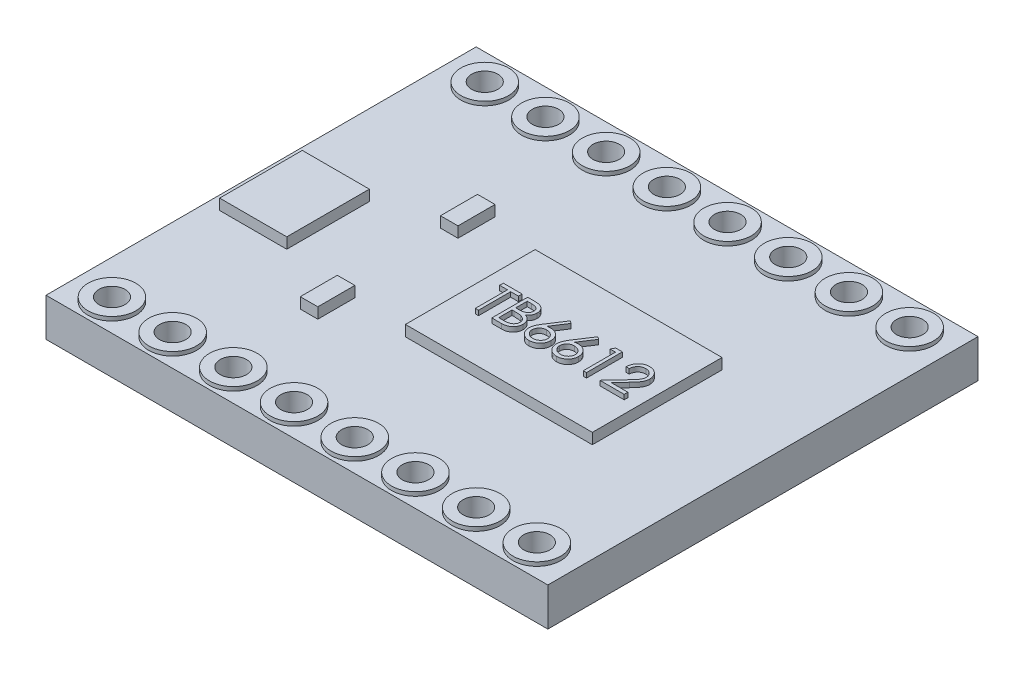
from build123d import *

# Parameters (mm, degrees)
SKETCH1_W           = 21
SKETCH1_H           = 18
SKETCH1_R           = 1
SKETCH1_W_2         = 7.822024276
SKETCH1_H_2         = 5.426675314
SKETCH1_W_3         = 2.807623522
SKETCH1_H_3         = 3.457148366
SKETCH1_W_4         = 0.733334502
SKETCH1_H_4         = 1.550478661
SKETCH1_H_5         = 1.550478662
BOSS_EXTRUDE1_DEPTH = 1.6
SKETCH1_4_W         = 0.733334502
SKETCH1_4_H         = 1.550478661
SKETCH1_4_W_2       = 2.807623522
SKETCH1_4_H_2       = 3.457148366
SKETCH1_4_H_3       = 1.550478662
SKETCH1_4_W_3       = 7.822024276
SKETCH1_4_H_4       = 5.426675314
BOSS_EXTRUDE2_DEPTH = 2.05
BOSS_EXTRUDE3_DEPTH = 0.2
SKETCH1_6_R         = 1
SKETCH1_6_R_2       = 0.55
BOSS_EXTRUDE4_DEPTH = 1.766276616


with BuildPart() as part:
    # Sketch1 → Boss-Extrude1 (new body)
    with BuildSketch(Plane(origin=(0, 0, 0), x_dir=(1, 0, 0), z_dir=(0, 1, 0))):
        with Locations((61.705593343, 83.060982754)):
            Rectangle(SKETCH1_W, SKETCH1_H)
        with Locations((52.815593343, 90.810982754)):
            Circle(SKETCH1_R, mode=Mode.SUBTRACT)
        with Locations((55.355593343, 90.810982754)):
            Circle(SKETCH1_R, mode=Mode.SUBTRACT)
        with Locations((57.895593343, 90.810982754)):
            Circle(SKETCH1_R, mode=Mode.SUBTRACT)
        with Locations((60.435593343, 90.810982754)):
            Circle(SKETCH1_R, mode=Mode.SUBTRACT)
        with Locations((62.975593343, 90.810982754)):
            Circle(SKETCH1_R, mode=Mode.SUBTRACT)
        with Locations((65.515593343, 90.810982754)):
            Circle(SKETCH1_R, mode=Mode.SUBTRACT)
        with Locations((68.055593343, 90.810982754)):
            Circle(SKETCH1_R, mode=Mode.SUBTRACT)
        with Locations((70.595593343, 90.810982754)):
            Circle(SKETCH1_R, mode=Mode.SUBTRACT)
        with Locations((55.355593343, 75.210982754)):
            Circle(SKETCH1_R, mode=Mode.SUBTRACT)
        with Locations((57.895593343, 75.210982754)):
            Circle(SKETCH1_R, mode=Mode.SUBTRACT)
        with Locations((60.435593343, 75.210982754)):
            Circle(SKETCH1_R, mode=Mode.SUBTRACT)
        with Locations((62.975593343, 75.210982754)):
            Circle(SKETCH1_R, mode=Mode.SUBTRACT)
        with Locations((65.515593343, 75.210982754)):
            Circle(SKETCH1_R, mode=Mode.SUBTRACT)
        with Locations((68.055593343, 75.210982754)):
            Circle(SKETCH1_R, mode=Mode.SUBTRACT)
        with Locations((70.595593343, 75.210982754)):
            Circle(SKETCH1_R, mode=Mode.SUBTRACT)
        with Locations((52.815593343, 75.210982754)):
            Circle(SKETCH1_R, mode=Mode.SUBTRACT)
        with Locations((64.144581205, 82.786474506)):
            Rectangle(SKETCH1_W_2, SKETCH1_H_2, mode=Mode.SUBTRACT)
        with Locations((53.172605435, 82.493140705)):
            Rectangle(SKETCH1_W_3, SKETCH1_H_3, mode=Mode.SUBTRACT)
        with Locations((57.394516924, 85.520764576)):
            Rectangle(SKETCH1_W_4, SKETCH1_H_4, mode=Mode.SUBTRACT)
        with Locations((57.394516924, 79.654088562)):
            Rectangle(SKETCH1_W_4, SKETCH1_H_5, mode=Mode.SUBTRACT)
    extrude(amount=BOSS_EXTRUDE1_DEPTH)

    # Sketch1_4 → Boss-Extrude2 (add)
    with BuildSketch(Plane(origin=(0, 0, 0), x_dir=(1, 0, 0), z_dir=(0, 1, 0))):
        with Locations((57.394516924, 85.520764576)):
            Rectangle(SKETCH1_4_W, SKETCH1_4_H)
        with Locations((53.172605435, 82.493140705)):
            Rectangle(SKETCH1_4_W_2, SKETCH1_4_H_2)
        with Locations((57.394516924, 79.654088562)):
            Rectangle(SKETCH1_4_W, SKETCH1_4_H_3)
        with Locations((64.144581205, 82.786474506)):
            Rectangle(SKETCH1_4_W_3, SKETCH1_4_H_4)
    extrude(amount=BOSS_EXTRUDE2_DEPTH)

    # Sketch3 → Boss-Extrude3 (add)
    with BuildSketch(Plane(origin=(0, 2.05, 0), x_dir=(1, 0, 0), z_dir=(0, 1, 0))):
        Polygon((60.986398195, 83.262831821), (60.986398195, 83.416677975), (61.774859733, 83.416677975), (61.774859733, 83.262831821), (61.447936656, 83.262831821), (61.447936656, 81.916677975), (61.313321272, 81.916677975), (61.313321272, 83.262831821), align=None)
        with BuildLine():
            Line((62.005628964, 83.416677975), (62.298297233, 83.416677975))
            add(Edge.make_bspline(
                [(62.298297233, 83.416677975), (62.312623724, 83.416602653), (62.340392028, 83.416456661), (62.380771789, 83.414192462), (62.418592708, 83.411105175), (62.453865753, 83.406206564), (62.486574626, 83.400295802), (62.516817899, 83.393137881), (62.544499401, 83.384555047), (62.577547717, 83.37090664), (62.615228, 83.350625283), (62.656027311, 83.320655898), (62.690914842, 83.283999128), (62.720994693, 83.242649418), (62.744909458, 83.197162659), (62.762210586, 83.148623006), (62.773163961, 83.097656546), (62.774290432, 83.062666612), (62.774859733, 83.044983263)],
                knots=[0, 0, 0, 0, 4.2973e-05, 8.3292e-05, 0.000121297, 0.00015678, 0.000190079, 0.000220981, 0.000249966, 0.000276917, 0.000328141, 0.000377961, 0.000428112, 0.000479321, 0.000530933, 0.000581687, 0.000633546, 0.000686534, 0.000686534, 0.000686534, 0.000686534], degree=3))
            add(Edge.make_bspline(
                [(62.774859733, 83.044983263), (62.774391211, 83.028417882), (62.773470521, 82.995865346), (62.764666481, 82.948253585), (62.750883337, 82.902931634), (62.731723945, 82.860064898), (62.706823089, 82.820621921), (62.677312381, 82.784284521), (62.641708037, 82.752591211), (62.615032363, 82.734872824), (62.601482329, 82.725872686)],
                knots=[0, 0, 0, 0, 4.9653e-05, 9.7573e-05, 0.000144717, 0.000191519, 0.000237957, 0.000284279, 0.000331517, 0.000380282, 0.000380282, 0.000380282, 0.000380282], degree=3))
            add(Edge.make_bspline(
                [(62.601482329, 82.725872686), (62.618522513, 82.719330544), (62.651124604, 82.706813805), (62.695990038, 82.68468432), (62.734644972, 82.660614844), (62.767386606, 82.634329766), (62.795388458, 82.605997418), (62.819839719, 82.575202369), (62.840703165, 82.541542902), (62.858580132, 82.505369958), (62.872529599, 82.4670529), (62.882976415, 82.426951139), (62.888962465, 82.385208472), (62.889814311, 82.356800453), (62.890244349, 82.342459225)],
                knots=[0, 0, 0, 0, 5.4738e-05, 0.000104727, 0.000149828, 0.000191077, 0.000230385, 0.000269101, 0.000308787, 0.000348967, 0.000389939, 0.000430898, 0.000473095, 0.000516115, 0.000516115, 0.000516115, 0.000516115], degree=3))
            add(Edge.make_bspline(
                [(62.890244349, 82.342459225), (62.8898257, 82.32781628), (62.889001998, 82.299005875), (62.882924867, 82.256682246), (62.87263525, 82.21623584), (62.858461902, 82.177405047), (62.839963767, 82.14026499), (62.817451782, 82.104773591), (62.790609683, 82.071287449), (62.760582739, 82.039434468), (62.726613249, 82.010793988), (62.689963639, 81.985287256), (62.650172359, 81.964310372), (62.607892933, 81.94668922), (62.562651084, 81.933228992), (62.514649966, 81.923812175), (62.46393098, 81.917467159), (62.429126801, 81.9169455), (62.411278002, 81.916677975)],
                knots=[0, 0, 0, 0, 4.3921e-05, 8.6415e-05, 0.000127955, 0.000168928, 0.000210182, 0.000252195, 0.000294758, 0.000338753, 0.000383306, 0.000427814, 0.000472444, 0.000517978, 0.000565035, 0.00061377, 0.000664607, 0.000718123, 0.000718123, 0.000718123, 0.000718123], degree=3))
            Line((62.411278002, 81.916677975), (62.005628964, 81.916677975))
            Line((62.005628964, 81.916677975), (62.005628964, 83.416677975))
        make_face()
        with BuildLine():
            Line((62.140244349, 83.262831821), (62.140244349, 82.78206259))
            Line((62.140244349, 82.78206259), (62.23068906, 82.78206259))
            add(Edge.make_bspline(
                [(62.23068906, 82.78206259), (62.243909972, 82.782233986), (62.269455469, 82.782565157), (62.306449711, 82.783513807), (62.340789004, 82.786170111), (62.372414075, 82.788825652), (62.401275123, 82.793143333), (62.427308206, 82.798282814), (62.450921891, 82.803718345), (62.478153125, 82.812962411), (62.509041531, 82.826624271), (62.541970004, 82.847826487), (62.570999063, 82.873079781), (62.595512143, 82.902218765), (62.615574202, 82.934304273), (62.629508651, 82.968824365), (62.638957487, 83.004918707), (62.639811001, 83.029697958), (62.640244349, 83.042278936)],
                knots=[0, 0, 0, 0, 3.9668e-05, 7.6647e-05, 0.000110986, 0.000142978, 0.000171832, 0.000198468, 0.000222591, 0.000244446, 0.000284658, 0.000323582, 0.000361488, 0.000399654, 0.00043743, 0.000474482, 0.000510993, 0.000548651, 0.000548651, 0.000548651, 0.000548651], degree=3))
            add(Edge.make_bspline(
                [(62.640244349, 83.042278936), (62.640018843, 83.050604267), (62.639576489, 83.066935312), (62.635953645, 83.090742178), (62.629796113, 83.113132358), (62.62188713, 83.134412691), (62.610834835, 83.15391777), (62.597821922, 83.172321996), (62.582099483, 83.188998619), (62.564203492, 83.204585546), (62.543628368, 83.21840463), (62.520386386, 83.230507814), (62.494163096, 83.240253861), (62.465400443, 83.248789355), (62.433655692, 83.254784338), (62.399295169, 83.259778647), (62.362037432, 83.262321251), (62.33626096, 83.262657835), (62.322936656, 83.262831821)],
                knots=[0, 0, 0, 0, 2.4969e-05, 4.8979e-05, 7.2012e-05, 9.4557e-05, 0.000116883, 0.000139064, 0.000162027, 0.00018546, 0.000210129, 0.000236202, 0.00026388, 0.000293928, 0.000326104, 0.000360694, 0.000398052, 0.000438026, 0.000438026, 0.000438026, 0.000438026], degree=3))
            Line((62.322936656, 83.262831821), (62.140244349, 83.262831821))
        make_face(mode=Mode.SUBTRACT)
        with BuildLine():
            Line((62.140244349, 82.628216436), (62.140244349, 82.070524129))
            Line((62.140244349, 82.070524129), (62.331951079, 82.070524129))
            add(Edge.make_bspline(
                [(62.331951079, 82.070524129), (62.345673476, 82.070688592), (62.372121587, 82.071005573), (62.410307828, 82.072040382), (62.445700587, 82.074394214), (62.47813836, 82.078099579), (62.507971411, 82.082118914), (62.534841855, 82.087523749), (62.558967509, 82.09371616), (62.586942213, 82.103287948), (62.618443716, 82.118157864), (62.652391226, 82.140578247), (62.682573891, 82.167288236), (62.708204716, 82.198201485), (62.729210283, 82.231814911), (62.744491192, 82.267448632), (62.753915845, 82.304513858), (62.755056775, 82.329785307), (62.755628964, 82.342459225)],
                knots=[0, 0, 0, 0, 4.117e-05, 7.935e-05, 0.000114589, 0.000147539, 0.000177285, 0.000204864, 0.000229717, 0.000251952, 0.000293486, 0.000333822, 0.000373623, 0.000413942, 0.000453884, 0.000492116, 0.000529866, 0.000567846, 0.000567846, 0.000567846, 0.000567846], degree=3))
            add(Edge.make_bspline(
                [(62.755628964, 82.342459225), (62.755510634, 82.350384942), (62.755275881, 82.366108534), (62.751735618, 82.389215314), (62.746586816, 82.411597831), (62.739930488, 82.433316863), (62.73023643, 82.453979738), (62.71891934, 82.473995121), (62.705650167, 82.493389469), (62.684974096, 82.517909007), (62.654900389, 82.546159155), (62.612168914, 82.573818084), (62.563580786, 82.596124288), (62.528340432, 82.605595492), (62.510136175, 82.610488071)],
                knots=[0, 0, 0, 0, 2.3755e-05, 4.7127e-05, 6.9942e-05, 9.2653e-05, 0.000115109, 0.000138254, 0.000161591, 0.000185483, 0.000234381, 0.000284718, 0.000337563, 0.000394031, 0.000394031, 0.000394031, 0.000394031], degree=3))
            add(Edge.make_bspline(
                [(62.510136175, 82.610488071), (62.502837992, 82.611968821), (62.487014023, 82.615179393), (62.461210775, 82.618568409), (62.431752545, 82.62158772), (62.398571312, 82.623821074), (62.361625094, 82.626129592), (62.320834986, 82.627027373), (62.276367566, 82.628098484), (62.245513692, 82.628176113), (62.229487137, 82.628216436)],
                knots=[0, 0, 0, 0, 2.2335e-05, 4.8427e-05, 7.8027e-05, 0.000111167, 0.000148186, 0.000189069, 0.000233549, 0.000281627, 0.000281627, 0.000281627, 0.000281627], degree=3))
            Line((62.229487137, 82.628216436), (62.140244349, 82.628216436))
        make_face(mode=Mode.SUBTRACT)
        with BuildLine():
            Line((63.755628964, 83.455139513), (63.859294829, 83.373709225))
            Line((63.859294829, 83.373709225), (63.462960695, 82.767639513))
            add(Edge.make_bspline(
                [(63.462960695, 82.767639513), (63.489347956, 82.771845454), (63.540819293, 82.780049616), (63.592918964, 82.781403021), (63.618309252, 82.78206259)],
                knots=[0, 0, 0, 0, 8.0061e-05, 0.000156168, 0.000156168, 0.000156168, 0.000156168], degree=3))
            add(Edge.make_bspline(
                [(63.618309252, 82.78206259), (63.633554608, 82.781652828), (63.663564637, 82.780846223), (63.707624695, 82.774638859), (63.74996281, 82.764856668), (63.790403501, 82.75059713), (63.829091922, 82.732381835), (63.866250092, 82.710550891), (63.901179525, 82.683977028), (63.93433003, 82.654292047), (63.964427358, 82.621413339), (63.991074238, 82.586527052), (64.013457149, 82.549669531), (64.031617401, 82.510859446), (64.045719492, 82.47015662), (64.055999911, 82.427613132), (64.06207688, 82.383199644), (64.06290209, 82.352994712), (64.063321272, 82.337651533)],
                knots=[0, 0, 0, 0, 4.5721e-05, 9.0001e-05, 0.000133222, 0.000175891, 0.000218368, 0.000261346, 0.000304916, 0.000349809, 0.000394681, 0.000438432, 0.000481307, 0.000523784, 0.000566737, 0.000610319, 0.000654897, 0.000700919, 0.000700919, 0.000700919, 0.000700919], degree=3))
            add(Edge.make_bspline(
                [(64.063321272, 82.337651533), (64.06271137, 82.316660231), (64.061511227, 82.275354317), (64.049552457, 82.215192871), (64.030969752, 82.157878936), (64.004407954, 82.104327577), (63.971415504, 82.05461219), (63.93118225, 82.010561276), (63.885135041, 81.971274117), (63.83306927, 81.93842128), (63.777036571, 81.911591401), (63.71817143, 81.892320583), (63.65704551, 81.880456239), (63.615557821, 81.878968838), (63.594571272, 81.878216436)],
                knots=[0, 0, 0, 0, 6.2904e-05, 0.00012378, 0.000183263, 0.000243197, 0.000302535, 0.000361677, 0.000421581, 0.000483597, 0.000545827, 0.000607495, 0.000668962, 0.000731884, 0.000731884, 0.000731884, 0.000731884], degree=3))
            add(Edge.make_bspline(
                [(63.594571272, 81.878216436), (63.574386971, 81.878871382), (63.534405407, 81.880168714), (63.475591352, 81.891725544), (63.41907863, 81.91045716), (63.365263181, 81.936263279), (63.31541149, 81.968859515), (63.270811931, 82.008100491), (63.231686885, 82.053147405), (63.199126333, 82.103993268), (63.173301163, 82.158631821), (63.153934052, 82.215604888), (63.142621376, 82.27470488), (63.141040566, 82.314768226), (63.140244349, 82.334947206)],
                knots=[0, 0, 0, 0, 6.0504e-05, 0.000119848, 0.000179046, 0.000238718, 0.000298389, 0.000357156, 0.000416376, 0.000476803, 0.000537689, 0.000597267, 0.000656906, 0.000717429, 0.000717429, 0.000717429, 0.000717429], degree=3))
            add(Edge.make_bspline(
                [(63.140244349, 82.334947206), (63.140750682, 82.350394884), (63.141784519, 82.381936092), (63.149003114, 82.42970639), (63.160602312, 82.478585425), (63.173592418, 82.520051508), (63.187317679, 82.554020731), (63.198740196, 82.581407942), (63.212957623, 82.609591259), (63.228117644, 82.639537103), (63.245584873, 82.670473717), (63.264577294, 82.702918147), (63.285620002, 82.736354401), (63.3003715, 82.759044771), (63.307912618, 82.770644321)],
                knots=[0, 0, 0, 0, 4.6336e-05, 9.461e-05, 0.000144609, 0.00019697, 0.000224757, 0.000254506, 0.000285952, 0.000319415, 0.000355196, 0.000392507, 0.000432193, 0.0004737, 0.0004737, 0.0004737, 0.0004737], degree=3))
            Line((63.307912618, 82.770644321), (63.755628964, 83.455139513))
        make_face()
        with BuildLine():
            add(Edge.make_bspline(
                [(63.59006406, 82.628216436), (63.578637384, 82.627882989), (63.556317765, 82.62723167), (63.523571731, 82.623449419), (63.492580337, 82.616326962), (63.462932994, 82.607255677), (63.435183979, 82.594782937), (63.409131619, 82.579632166), (63.384675168, 82.561794518), (63.362070789, 82.541522699), (63.341576647, 82.519327828), (63.323927591, 82.495555176), (63.308703705, 82.47077766), (63.296325783, 82.444788256), (63.286687179, 82.417596899), (63.279715071, 82.38932865), (63.275834892, 82.359793947), (63.275189365, 82.339765731), (63.274859733, 82.329538552)],
                knots=[0, 0, 0, 0, 3.4288e-05, 6.6974e-05, 9.8686e-05, 0.000129571, 0.000159836, 0.000189728, 0.000219839, 0.000250482, 0.00028068, 0.000310307, 0.000339166, 0.000367794, 0.000396495, 0.000425574, 0.000454981, 0.000485667, 0.000485667, 0.000485667, 0.000485667], degree=3))
            add(Edge.make_bspline(
                [(63.274859733, 82.329538552), (63.275128174, 82.319402846), (63.275654546, 82.299528236), (63.280434112, 82.270240016), (63.287734861, 82.242055056), (63.298595031, 82.215118656), (63.311549411, 82.189020234), (63.328651693, 82.164705112), (63.347601744, 82.14069651), (63.37025343, 82.118838737), (63.394563443, 82.098500184), (63.420535387, 82.080722932), (63.447603941, 82.065514572), (63.47613455, 82.05359553), (63.505722429, 82.043813693), (63.536614095, 82.036930202), (63.568831033, 82.033038548), (63.590654721, 82.032392179), (63.60178281, 82.03206259)],
                knots=[0, 0, 0, 0, 3.0386e-05, 5.9582e-05, 8.8809e-05, 0.000117545, 0.000146572, 0.000175992, 0.000206542, 0.000238201, 0.000270211, 0.000301549, 0.000332485, 0.000363181, 0.000394158, 0.00042587, 0.00045796, 0.000491347, 0.000491347, 0.000491347, 0.000491347], degree=3))
            add(Edge.make_bspline(
                [(63.60178281, 82.03206259), (63.612910881, 82.032392205), (63.634734533, 82.033038624), (63.66695173, 82.036929911), (63.697842438, 82.04381476), (63.727433799, 82.053591662), (63.755951555, 82.065528923), (63.782996436, 82.080628317), (63.808722762, 82.09860951), (63.833048733, 82.11880398), (63.855606135, 82.140820916), (63.875010683, 82.164490797), (63.891589212, 82.189216752), (63.905061006, 82.215015848), (63.915801559, 82.242071343), (63.923139331, 82.270235653), (63.927909026, 82.299529378), (63.928436755, 82.319403232), (63.928705887, 82.329538552)],
                knots=[0, 0, 0, 0, 3.3387e-05, 6.5477e-05, 9.7189e-05, 0.000128166, 0.000158862, 0.000189798, 0.000220889, 0.000252898, 0.000284557, 0.000315298, 0.000344549, 0.000373715, 0.000402451, 0.000431678, 0.000460874, 0.00049126, 0.00049126, 0.00049126, 0.00049126], degree=3))
            add(Edge.make_bspline(
                [(63.928705887, 82.329538552), (63.928470047, 82.339779074), (63.92800717, 82.359877887), (63.922771764, 82.389315438), (63.915510746, 82.417740527), (63.90454659, 82.444974505), (63.890302357, 82.470909902), (63.872952325, 82.495677731), (63.852881224, 82.51946788), (63.829696564, 82.541566226), (63.804457892, 82.561772117), (63.777622641, 82.57960907), (63.749547795, 82.594662631), (63.72026182, 82.607222818), (63.689429156, 82.616286878), (63.657547582, 82.623423982), (63.624209335, 82.62722199), (63.601590789, 82.627880732), (63.59006406, 82.628216436)],
                knots=[0, 0, 0, 0, 3.0686e-05, 6.0226e-05, 8.9453e-05, 0.00011858, 0.000148029, 0.000178036, 0.000209162, 0.000241251, 0.000273959, 0.000306045, 0.000337772, 0.000369416, 0.000401449, 0.000434041, 0.000467324, 0.000501912, 0.000501912, 0.000501912, 0.000501912], degree=3))
        make_face(mode=Mode.SUBTRACT)
        with BuildLine():
            Line((64.909475118, 83.455139513), (65.013140983, 83.373709225))
            Line((65.013140983, 83.373709225), (64.616806849, 82.767639513))
            add(Edge.make_bspline(
                [(64.616806849, 82.767639513), (64.64319411, 82.771845454), (64.694665447, 82.780049616), (64.746765118, 82.781403021), (64.772155406, 82.78206259)],
                knots=[0, 0, 0, 0, 8.0061e-05, 0.000156168, 0.000156168, 0.000156168, 0.000156168], degree=3))
            add(Edge.make_bspline(
                [(64.772155406, 82.78206259), (64.787400762, 82.781652828), (64.817410791, 82.780846223), (64.861470849, 82.774638859), (64.903808964, 82.764856668), (64.944249655, 82.75059713), (64.982938076, 82.732381835), (65.020096246, 82.710550891), (65.055025679, 82.683977028), (65.088176184, 82.654292047), (65.118273511, 82.621413339), (65.144920392, 82.586527052), (65.167303303, 82.549669531), (65.185463555, 82.510859446), (65.199565646, 82.47015662), (65.209846065, 82.427613132), (65.215923034, 82.383199644), (65.216748244, 82.352994712), (65.217167425, 82.337651533)],
                knots=[0, 0, 0, 0, 4.5721e-05, 9.0001e-05, 0.000133222, 0.000175891, 0.000218368, 0.000261346, 0.000304916, 0.000349809, 0.000394681, 0.000438432, 0.000481307, 0.000523784, 0.000566737, 0.000610319, 0.000654897, 0.000700919, 0.000700919, 0.000700919, 0.000700919], degree=3))
            add(Edge.make_bspline(
                [(65.217167425, 82.337651533), (65.216557523, 82.316660231), (65.21535738, 82.275354317), (65.203398611, 82.215192871), (65.184815906, 82.157878936), (65.158254108, 82.104327577), (65.125261658, 82.05461219), (65.085028404, 82.010561276), (65.038981195, 81.971274117), (64.986915424, 81.93842128), (64.930882725, 81.911591401), (64.872017583, 81.892320583), (64.810891664, 81.880456239), (64.769403974, 81.878968838), (64.748417425, 81.878216436)],
                knots=[0, 0, 0, 0, 6.2904e-05, 0.00012378, 0.000183263, 0.000243197, 0.000302535, 0.000361677, 0.000421581, 0.000483597, 0.000545827, 0.000607495, 0.000668962, 0.000731884, 0.000731884, 0.000731884, 0.000731884], degree=3))
            add(Edge.make_bspline(
                [(64.748417425, 81.878216436), (64.728233125, 81.878871382), (64.68825156, 81.880168714), (64.629437506, 81.891725544), (64.572924784, 81.91045716), (64.519109335, 81.936263279), (64.469257644, 81.968859515), (64.424658085, 82.008100491), (64.385533039, 82.053147405), (64.352972487, 82.103993268), (64.327147316, 82.158631821), (64.307780206, 82.215604888), (64.29646753, 82.27470488), (64.29488672, 82.314768226), (64.294090502, 82.334947206)],
                knots=[0, 0, 0, 0, 6.0504e-05, 0.000119848, 0.000179046, 0.000238718, 0.000298389, 0.000357156, 0.000416376, 0.000476803, 0.000537689, 0.000597267, 0.000656906, 0.000717429, 0.000717429, 0.000717429, 0.000717429], degree=3))
            add(Edge.make_bspline(
                [(64.294090502, 82.334947206), (64.294596836, 82.350394884), (64.295630672, 82.381936092), (64.302849268, 82.42970639), (64.314448466, 82.478585425), (64.327438572, 82.520051508), (64.341163833, 82.554020731), (64.35258635, 82.581407942), (64.366803777, 82.609591259), (64.381963797, 82.639537103), (64.399431027, 82.670473717), (64.418423448, 82.702918147), (64.439466156, 82.736354401), (64.454217654, 82.759044771), (64.461758772, 82.770644321)],
                knots=[0, 0, 0, 0, 4.6336e-05, 9.461e-05, 0.000144609, 0.00019697, 0.000224757, 0.000254506, 0.000285952, 0.000319415, 0.000355196, 0.000392507, 0.000432193, 0.0004737, 0.0004737, 0.0004737, 0.0004737], degree=3))
            Line((64.461758772, 82.770644321), (64.909475118, 83.455139513))
        make_face()
        with BuildLine():
            add(Edge.make_bspline(
                [(64.743910214, 82.628216436), (64.732483538, 82.627882989), (64.710163919, 82.62723167), (64.677417884, 82.623449419), (64.646426491, 82.616326962), (64.616779148, 82.607255677), (64.589030132, 82.594782937), (64.562977772, 82.579632166), (64.538521322, 82.561794518), (64.515916942, 82.541522699), (64.495422801, 82.519327828), (64.477773745, 82.495555176), (64.462549859, 82.47077766), (64.450171937, 82.444788256), (64.440533333, 82.417596899), (64.433561225, 82.38932865), (64.429681046, 82.359793947), (64.429035518, 82.339765731), (64.428705887, 82.329538552)],
                knots=[0, 0, 0, 0, 3.4288e-05, 6.6974e-05, 9.8686e-05, 0.000129571, 0.000159836, 0.000189728, 0.000219839, 0.000250482, 0.00028068, 0.000310307, 0.000339166, 0.000367794, 0.000396495, 0.000425574, 0.000454981, 0.000485667, 0.000485667, 0.000485667, 0.000485667], degree=3))
            add(Edge.make_bspline(
                [(64.428705887, 82.329538552), (64.428974328, 82.319402846), (64.4295007, 82.299528236), (64.434280265, 82.270240016), (64.441581015, 82.242055056), (64.452441185, 82.215118656), (64.465395565, 82.189020234), (64.482497847, 82.164705112), (64.501447898, 82.14069651), (64.524099584, 82.118838737), (64.548409597, 82.098500184), (64.574381541, 82.080722932), (64.601450095, 82.065514572), (64.629980704, 82.05359553), (64.659568583, 82.043813693), (64.690460249, 82.036930202), (64.722677187, 82.033038548), (64.744500875, 82.032392179), (64.755628964, 82.03206259)],
                knots=[0, 0, 0, 0, 3.0386e-05, 5.9582e-05, 8.8809e-05, 0.000117545, 0.000146572, 0.000175992, 0.000206542, 0.000238201, 0.000270211, 0.000301549, 0.000332485, 0.000363181, 0.000394158, 0.00042587, 0.00045796, 0.000491347, 0.000491347, 0.000491347, 0.000491347], degree=3))
            add(Edge.make_bspline(
                [(64.755628964, 82.03206259), (64.766757035, 82.032392205), (64.788580687, 82.033038624), (64.820797884, 82.036929911), (64.851688592, 82.04381476), (64.881279953, 82.053591662), (64.909797709, 82.065528923), (64.93684259, 82.080628317), (64.962568915, 82.09860951), (64.986894887, 82.11880398), (65.009452289, 82.140820916), (65.028856837, 82.164490797), (65.045435365, 82.189216752), (65.05890716, 82.215015848), (65.069647713, 82.242071343), (65.076985485, 82.270235653), (65.08175518, 82.299529378), (65.082282909, 82.319403232), (65.082552041, 82.329538552)],
                knots=[0, 0, 0, 0, 3.3387e-05, 6.5477e-05, 9.7189e-05, 0.000128166, 0.000158862, 0.000189798, 0.000220889, 0.000252898, 0.000284557, 0.000315298, 0.000344549, 0.000373715, 0.000402451, 0.000431678, 0.000460874, 0.00049126, 0.00049126, 0.00049126, 0.00049126], degree=3))
            add(Edge.make_bspline(
                [(65.082552041, 82.329538552), (65.082316201, 82.339779074), (65.081853324, 82.359877887), (65.076617918, 82.389315438), (65.0693569, 82.417740527), (65.058392744, 82.444974505), (65.044148511, 82.470909902), (65.026798479, 82.495677731), (65.006727378, 82.51946788), (64.983542718, 82.541566226), (64.958304046, 82.561772117), (64.931468795, 82.57960907), (64.903393949, 82.594662631), (64.874107974, 82.607222818), (64.84327531, 82.616286878), (64.811393736, 82.623423982), (64.778055489, 82.62722199), (64.755436943, 82.627880732), (64.743910214, 82.628216436)],
                knots=[0, 0, 0, 0, 3.0686e-05, 6.0226e-05, 8.9453e-05, 0.00011858, 0.000148029, 0.000178036, 0.000209162, 0.000241251, 0.000273959, 0.000306045, 0.000337772, 0.000369416, 0.000401449, 0.000434041, 0.000467324, 0.000501912, 0.000501912, 0.000501912, 0.000501912], degree=3))
        make_face(mode=Mode.SUBTRACT)
        Polygon((65.689823675, 83.416677975), (65.967167425, 83.416677975), (65.967167425, 81.916677975), (65.832552041, 81.916677975), (65.832552041, 83.262831821), (65.60178281, 83.262831821), align=None)
        with BuildLine():
            Line((66.717167425, 82.955139513), (66.582552041, 82.955139513))
            add(Edge.make_bspline(
                [(66.582552041, 82.955139513), (66.583429392, 82.972998465), (66.585152487, 83.008072971), (66.593221754, 83.059211788), (66.604767844, 83.108092416), (66.621092753, 83.15432238), (66.641366872, 83.19831044), (66.665679741, 83.239881875), (66.694477105, 83.278878099), (66.727137134, 83.314937603), (66.762609408, 83.348017991), (66.800883382, 83.376584523), (66.841102679, 83.400720668), (66.883145279, 83.420898343), (66.92748552, 83.436043991), (66.973721031, 83.447281837), (67.022054947, 83.454043128), (67.054986385, 83.454769893), (67.071734733, 83.455139513)],
                knots=[0, 0, 0, 0, 5.3607e-05, 0.000105283, 0.000155059, 0.000204096, 0.000252092, 0.000300173, 0.000348312, 0.000397247, 0.000445941, 0.000493597, 0.000540234, 0.00058647, 0.000633223, 0.000680522, 0.000729051, 0.000779276, 0.000779276, 0.000779276, 0.000779276], degree=3))
            add(Edge.make_bspline(
                [(67.071734733, 83.455139513), (67.088182479, 83.454754461), (67.120501713, 83.453997846), (67.167671147, 83.447500262), (67.212575702, 83.437323579), (67.255127602, 83.423045544), (67.294987344, 83.403852218), (67.332454363, 83.38079613), (67.367974711, 83.354130488), (67.399949046, 83.322735996), (67.429309652, 83.289220689), (67.45463919, 83.253440159), (67.476330546, 83.21648475), (67.49441098, 83.178072664), (67.507720754, 83.137842223), (67.5178257, 83.096379136), (67.523537449, 83.053254217), (67.524414059, 83.024065694), (67.524859733, 83.009226052)],
                knots=[0, 0, 0, 0, 4.9324e-05, 9.6919e-05, 0.000142549, 0.000187304, 0.000231254, 0.000274955, 0.000319127, 0.000364179, 0.000409123, 0.000452646, 0.000495472, 0.00053755, 0.00057974, 0.000622375, 0.000665424, 0.000709944, 0.000709944, 0.000709944, 0.000709944], degree=3))
            add(Edge.make_bspline(
                [(67.524859733, 83.009226052), (67.524134049, 82.988334123), (67.522695416, 82.946916888), (67.510389254, 82.886053376), (67.491169321, 82.827084767), (67.468027597, 82.779625924), (67.444682263, 82.741382998), (67.42364476, 82.70989641), (67.399016984, 82.675994066), (67.370440485, 82.639789493), (67.338506397, 82.600999105), (67.30292547, 82.559646336), (67.263443977, 82.516158434), (67.235733191, 82.486456034), (67.221374156, 82.471064994)],
                knots=[0, 0, 0, 0, 6.2622e-05, 0.000124145, 0.000185528, 0.000248289, 0.000281991, 0.00031991, 0.000361862, 0.000407665, 0.000458258, 0.000512588, 0.000571306, 0.000634453, 0.000634453, 0.000634453, 0.000634453], degree=3))
            Line((67.221374156, 82.471064994), (66.846073675, 82.070524129))
            Line((66.846073675, 82.070524129), (67.544090502, 82.070524129))
            Line((67.544090502, 82.070524129), (67.544090502, 81.916677975))
            Line((67.544090502, 81.916677975), (66.524859733, 81.916677975))
            Line((66.524859733, 81.916677975), (67.106590502, 82.537471244))
            add(Edge.make_bspline(
                [(67.106590502, 82.537471244), (67.120753882, 82.552256233), (67.147958837, 82.58065517), (67.186437084, 82.622116438), (67.220996651, 82.660580527), (67.251861247, 82.695974762), (67.278361321, 82.728816863), (67.301877992, 82.758043164), (67.320720388, 82.784937929), (67.341169843, 82.816112478), (67.360975836, 82.854174899), (67.377995417, 82.900689337), (67.388373209, 82.948572446), (67.389618138, 82.980930462), (67.390244349, 82.997206821)],
                knots=[0, 0, 0, 0, 6.1422e-05, 0.00011798, 0.000169684, 0.000216552, 0.000258835, 0.000296285, 0.000329049, 0.000357304, 0.000408106, 0.000457344, 0.000505551, 0.000554341, 0.000554341, 0.000554341, 0.000554341], degree=3))
            add(Edge.make_bspline(
                [(67.390244349, 82.997206821), (67.389971888, 83.007441706), (67.389434919, 83.027612699), (67.384695906, 83.057186596), (67.377534261, 83.085714373), (67.367272007, 83.113283781), (67.353726261, 83.139617632), (67.33723767, 83.164747981), (67.318213357, 83.189043252), (67.29620567, 83.211823237), (67.272029305, 83.23268661), (67.246488912, 83.251168361), (67.219467439, 83.266613694), (67.191078815, 83.279275193), (67.161402185, 83.289207499), (67.130380152, 83.296089748), (67.09809843, 83.300410812), (67.076055504, 83.300995457), (67.064823675, 83.301293359)],
                knots=[0, 0, 0, 0, 3.0686e-05, 6.0476e-05, 8.9627e-05, 0.000118817, 0.000148516, 0.00017827, 0.000208867, 0.000240957, 0.000273125, 0.000304562, 0.000335385, 0.000366321, 0.000397678, 0.000429096, 0.000461522, 0.000495209, 0.000495209, 0.000495209, 0.000495209], degree=3))
            add(Edge.make_bspline(
                [(67.064823675, 83.301293359), (67.053093319, 83.300986917), (67.030056835, 83.300385115), (66.996234392, 83.296175402), (66.963969059, 83.288912899), (66.933179672, 83.278980038), (66.903814135, 83.266354946), (66.876015259, 83.250629912), (66.849845449, 83.231865558), (66.825255511, 83.210591034), (66.80259952, 83.186904919), (66.782693716, 83.160500649), (66.765300567, 83.131860328), (66.750125181, 83.101061235), (66.737801314, 83.067823901), (66.728384249, 83.032266313), (66.720932744, 82.994542864), (66.718443378, 82.968492113), (66.717167425, 82.955139513)],
                knots=[0, 0, 0, 0, 3.5188e-05, 6.9104e-05, 0.000102054, 0.000134268, 0.000166029, 0.000197784, 0.000229884, 0.000262476, 0.000295208, 0.000328021, 0.000361466, 0.0003956, 0.000430874, 0.000467611, 0.000505858, 0.000546075, 0.000546075, 0.000546075, 0.000546075], degree=3))
        make_face()
    extrude(amount=BOSS_EXTRUDE3_DEPTH)

    # Sketch1_6 → Boss-Extrude4 (add)
    with BuildSketch(Plane(origin=(0, 0, 0), x_dir=(1, 0, 0), z_dir=(0, 1, 0))):
        with Locations((52.815593343, 90.810982754)):
            Circle(SKETCH1_6_R)
        with Locations((52.815593343, 90.810982754)):
            Circle(SKETCH1_6_R_2, mode=Mode.SUBTRACT)
        with Locations((55.355593343, 90.810982754)):
            Circle(SKETCH1_6_R)
        with Locations((55.355593343, 90.810982754)):
            Circle(SKETCH1_6_R_2, mode=Mode.SUBTRACT)
        with Locations((57.895593343, 90.810982754)):
            Circle(SKETCH1_6_R)
        with Locations((57.895593343, 90.810982754)):
            Circle(SKETCH1_6_R_2, mode=Mode.SUBTRACT)
        with Locations((60.435593343, 90.810982754)):
            Circle(SKETCH1_6_R)
        with Locations((60.435593343, 90.810982754)):
            Circle(SKETCH1_6_R_2, mode=Mode.SUBTRACT)
        with Locations((62.975593343, 90.810982754)):
            Circle(SKETCH1_6_R)
        with Locations((62.975593343, 90.810982754)):
            Circle(SKETCH1_6_R_2, mode=Mode.SUBTRACT)
        with Locations((65.515593343, 90.810982754)):
            Circle(SKETCH1_6_R)
        with Locations((65.515593343, 90.810982754)):
            Circle(SKETCH1_6_R_2, mode=Mode.SUBTRACT)
        with Locations((68.055593343, 90.810982754)):
            Circle(SKETCH1_6_R)
        with Locations((68.055593343, 90.810982754)):
            Circle(SKETCH1_6_R_2, mode=Mode.SUBTRACT)
        with Locations((70.595593343, 90.810982754)):
            Circle(SKETCH1_6_R)
        with Locations((70.595593343, 90.810982754)):
            Circle(SKETCH1_6_R_2, mode=Mode.SUBTRACT)
        with Locations((70.595593343, 75.210982754)):
            Circle(SKETCH1_6_R)
        with Locations((70.595593343, 75.210982754)):
            Circle(SKETCH1_6_R_2, mode=Mode.SUBTRACT)
        with Locations((68.055593343, 75.210982754)):
            Circle(SKETCH1_6_R)
        with Locations((68.055593343, 75.210982754)):
            Circle(SKETCH1_6_R_2, mode=Mode.SUBTRACT)
        with Locations((65.515593343, 75.210982754)):
            Circle(SKETCH1_6_R)
        with Locations((65.515593343, 75.210982754)):
            Circle(SKETCH1_6_R_2, mode=Mode.SUBTRACT)
        with Locations((62.975593343, 75.210982754)):
            Circle(SKETCH1_6_R)
        with Locations((62.975593343, 75.210982754)):
            Circle(SKETCH1_6_R_2, mode=Mode.SUBTRACT)
        with Locations((60.435593343, 75.210982754)):
            Circle(SKETCH1_6_R)
        with Locations((60.435593343, 75.210982754)):
            Circle(SKETCH1_6_R_2, mode=Mode.SUBTRACT)
        with Locations((57.895593343, 75.210982754)):
            Circle(SKETCH1_6_R)
        with Locations((57.895593343, 75.210982754)):
            Circle(SKETCH1_6_R_2, mode=Mode.SUBTRACT)
        with Locations((52.815593343, 75.210982754)):
            Circle(SKETCH1_6_R)
        with Locations((52.815593343, 75.210982754)):
            Circle(SKETCH1_6_R_2, mode=Mode.SUBTRACT)
        with Locations((55.355593343, 75.210982754)):
            Circle(SKETCH1_6_R)
        with Locations((55.355593343, 75.210982754)):
            Circle(SKETCH1_6_R_2, mode=Mode.SUBTRACT)
    extrude(amount=BOSS_EXTRUDE4_DEPTH)


solid = part.part
